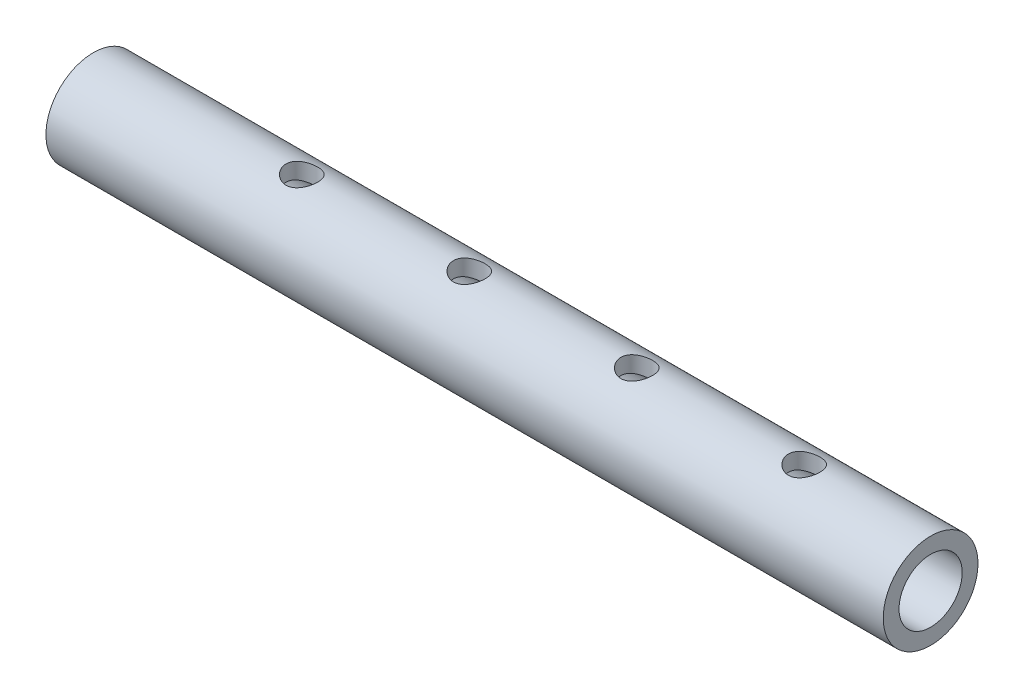
from build123d import *

# Parameters (mm, degrees)
SWEEP_THIN1_PROFILE_R   = 15
SWEEP_THIN1_PROFILE_R_2 = 10
SKETCH3_R               = 5
CUT_EXTRUDE1_DEPTH      = 371.070563812
CUT_EXTRUDE1_DEPTH_BACK = 371.070563812


with BuildPart() as part:
    # Sweep-Thin1: sweep along a path in Sketch2
    with BuildLine(Plane(origin=(0, 0, 0), x_dir=(1, 0, 0), z_dir=(0, 1, 0))) as sweep_thin1_path:
        Line((49.169098098, 180), (314.169098098, 180))
    # Sweep-Thin1 profile (on start of the path) → Sweep-Thin1 (sweep)
    with BuildSketch(Plane(origin=(49.169098098, 0, -180), x_dir=(0, 0, 1), z_dir=(1, 0, 0))):
        Circle(SWEEP_THIN1_PROFILE_R)
        Circle(SWEEP_THIN1_PROFILE_R_2, mode=Mode.SUBTRACT)
    sweep(path=sweep_thin1_path.line)

    # Sketch3 → Cut-Extrude1 (cut, two sides)
    with BuildSketch(Plane(origin=(0, 0, 0), x_dir=(1, 0, 0), z_dir=(0, 1, 0))) as cut_extrude1_sk:
        with Locations(Location((115.169098098, 180, 0), (0, 0, 270))):
            Circle(SKETCH3_R)
        with Locations(Location((168.169098098, 180, 0), (0, 0, 270))):
            Circle(SKETCH3_R)
        with Locations(Location((221.169098098, 180, 0), (0, 0, 270))):
            Circle(SKETCH3_R)
        with Locations(Location((274.169098098, 180, 0), (0, 0, 270))):
            Circle(SKETCH3_R)
    extrude(amount=CUT_EXTRUDE1_DEPTH, mode=Mode.SUBTRACT)
    extrude(cut_extrude1_sk.sketch, amount=-CUT_EXTRUDE1_DEPTH_BACK, mode=Mode.SUBTRACT)


solid = part.part
